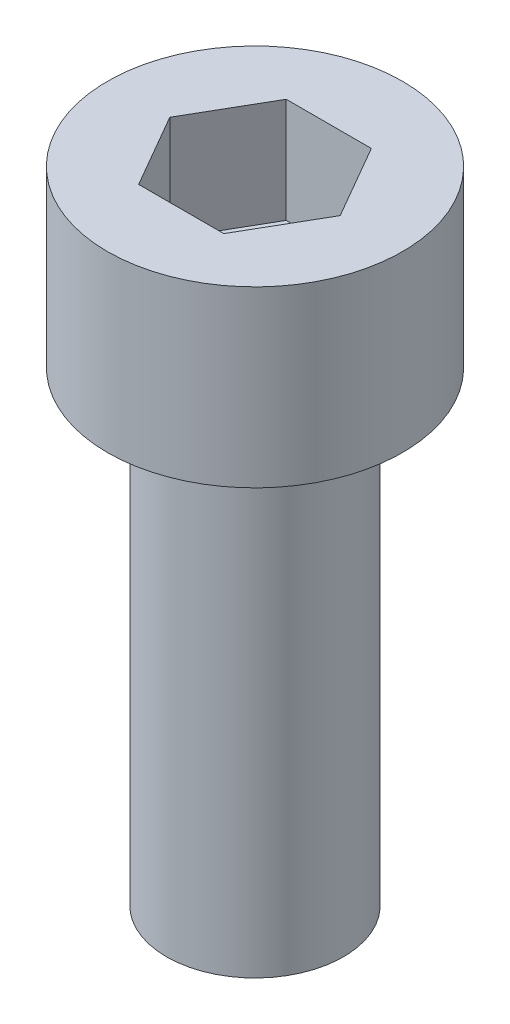
from build123d import *

# Parameters (mm, degrees)
SKETCH1_R           = 1.5
BOSS_EXTRUDE1_DEPTH = 7.9
SKETCH3_W           = 2.5
SKETCH3_H           = 2.95
CUT_EXTRUDE1_DEPTH  = 1.778


with BuildPart() as part:
    # Sketch1 → Boss-Extrude1 (new body)
    with BuildSketch(Plane(origin=(0, 0, 0), x_dir=(1, 0, 0), z_dir=(0, 1, 0))):
        Circle(SKETCH1_R)
    extrude(amount=BOSS_EXTRUDE1_DEPTH)

    # Sketch3 → Revolve1 (revolve)
    with BuildSketch(Plane.XY):
        with Locations((1.25, 9.375)):
            Rectangle(SKETCH3_W, SKETCH3_H)
    revolve(axis=Axis((0, 7.9, 0), (0, 1, 0)))

    # Sketch4 → Cut-Extrude1 (cut)
    with BuildSketch(Plane(origin=(0, 10.85, 0), x_dir=(1, 0, 0), z_dir=(0, 1, 0))):
        Polygon((1.443375673, 0), (0.721687836, 1.25), (-0.721687836, 1.25), (-1.443375673, 0), (-0.721687836, -1.25), (0.721687836, -1.25), align=None)
    extrude(amount=-CUT_EXTRUDE1_DEPTH, mode=Mode.SUBTRACT)


solid = part.part
